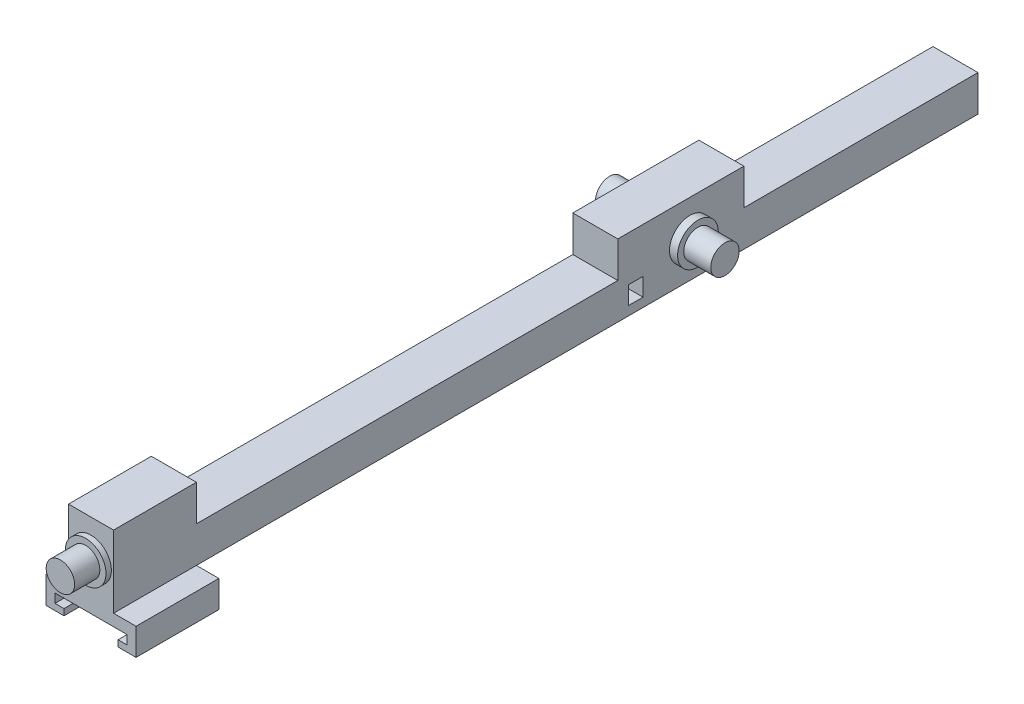
from build123d import *

# Parameters (mm, degrees)
BOSS_EXTRUDE1_DEPTH = 20
SKETCH2_R           = 5.65
BOSS_EXTRUDE2_DEPTH = 1.5
SKETCH3_R           = 3.95
BOSS_EXTRUDE3_DEPTH = 7
SKETCH4_R           = 5.65
BOSS_EXTRUDE4_DEPTH = 2.25
SKETCH5_R           = 3.95
BOSS_EXTRUDE5_DEPTH = 7.5
SKETCH9_W           = 25
SKETCH9_H           = 7.5
BOSS_EXTRUDE8_DEPTH = 23
CUT_EXTRUDE1_DEPTH  = 20
CUT_EXTRUDE2_REACH  = 173.135
SKETCH12_W          = 4
SKETCH12_H          = 5
CUT_EXTRUDE3_REACH  = 173.135
SKETCH14_W          = 65
SKETCH14_H          = 10
SKETCH14_W_2        = 117


with BuildPart() as part:
    # Sketch1 → Boss-Extrude1 (new body)
    with BuildSketch(Plane(origin=(0, 0, 0), x_dir=(1, 0, 0), z_dir=(0, 1, 0))):
        Polygon((-6.25, 80), (6.25, 80), (6.25, 0), (6.25, -160), (-6.25, -160), align=None)
    extrude(amount=BOSS_EXTRUDE1_DEPTH)

    # Sketch2 → Boss-Extrude2 (add)
    with BuildSketch(Plane.XY.offset(160)):
        with Locations(Location((0, 10, 0), (0, 0, 180))):
            Circle(SKETCH2_R)
    extrude(amount=BOSS_EXTRUDE2_DEPTH)

    # Sketch3 → Boss-Extrude3 (add)
    with BuildSketch(Plane.XY.offset(161.5)):
        with Locations(Location((0, 10, 0), (0, 0, 180))):
            Circle(SKETCH3_R)
    extrude(amount=BOSS_EXTRUDE3_DEPTH)

    # Sketch4 → Boss-Extrude4 (add)
    with BuildSketch(Plane.ZY.offset(6.25)):
        with Locations(Location((0, 10, 0), (0, 0, 180))):
            Circle(SKETCH4_R)
    boss_extrude4 = extrude(amount=BOSS_EXTRUDE4_DEPTH)

    # Sketch5 → Boss-Extrude5 (add)
    with BuildSketch(Plane.ZY.offset(8.5)):
        with Locations((0, 10)):
            Circle(SKETCH5_R)
    boss_extrude5 = extrude(amount=BOSS_EXTRUDE5_DEPTH)

    # Mirror1: Boss-Extrude4, Boss-Extrude5 across plane
    add(boss_extrude4.mirror(Plane(origin=(0, 0, 0), x_dir=(0, 0, 1), z_dir=(1, 0, 0))))
    add(boss_extrude5.mirror(Plane(origin=(0, 0, 0), x_dir=(0, 0, 1), z_dir=(1, 0, 0))))

    # Sketch9 → Boss-Extrude8 (add)
    with BuildSketch(Plane.XY.offset(160)):
        with Locations((0, -3.75)):
            Rectangle(SKETCH9_W, SKETCH9_H)
    extrude(amount=-BOSS_EXTRUDE8_DEPTH)

    # Sketch10 → Cut-Extrude1 (cut)
    with BuildSketch(Plane.XY.offset(160)):
        Polygon((-10, -5.75), (-10, -3.25), (10, -3.25), (10, -5.75), (7.5, -5.75), (7.5, -7.5), (-7.5, -7.5), (-7.5, -5.75), align=None)
    extrude(amount=-CUT_EXTRUDE1_DEPTH, mode=Mode.SUBTRACT)

    # Sketch12 → Cut-Extrude2 (cut, up to next)
    with BuildSketch(Plane.ZY.offset(6.25), mode=Mode.PRIVATE) as cut_extrude2_sk1:
        with Locations((15, 5)):
            Rectangle(SKETCH12_W, SKETCH12_H)
    cut_extrude2_tool1 = extrude(cut_extrude2_sk1.sketch, amount=-CUT_EXTRUDE2_REACH, mode=Mode.PRIVATE) & part.part
    add(cut_extrude2_tool1.solids().sort_by_distance((-6.25, 5, 15))[0], mode=Mode.SUBTRACT)

    # Sketch14 → Cut-Extrude3 (cut, up to next)
    with BuildSketch(Plane.ZY.offset(6.25), mode=Mode.PRIVATE) as cut_extrude3_sk1:
        with Locations((-47.5, 15)):
            Rectangle(SKETCH14_W, SKETCH14_H)
    cut_extrude3_tool1 = extrude(cut_extrude3_sk1.sketch, amount=-CUT_EXTRUDE3_REACH, mode=Mode.PRIVATE) & part.part
    # Sketch14 → Cut-Extrude3 (cut, up to next)
    with BuildSketch(Plane.ZY.offset(6.25), mode=Mode.PRIVATE) as cut_extrude3_sk2:
        with Locations((78.5, 15)):
            Rectangle(SKETCH14_W_2, SKETCH14_H)
    cut_extrude3_tool2 = extrude(cut_extrude3_sk2.sketch, amount=-CUT_EXTRUDE3_REACH, mode=Mode.PRIVATE) & part.part
    add(cut_extrude3_tool1.solids().sort_by_distance((-6.25, 15, -47.5))[0], mode=Mode.SUBTRACT)
    add(cut_extrude3_tool2.solids().sort_by_distance((-6.25, 15, 78.5))[0], mode=Mode.SUBTRACT)


solid = part.part
